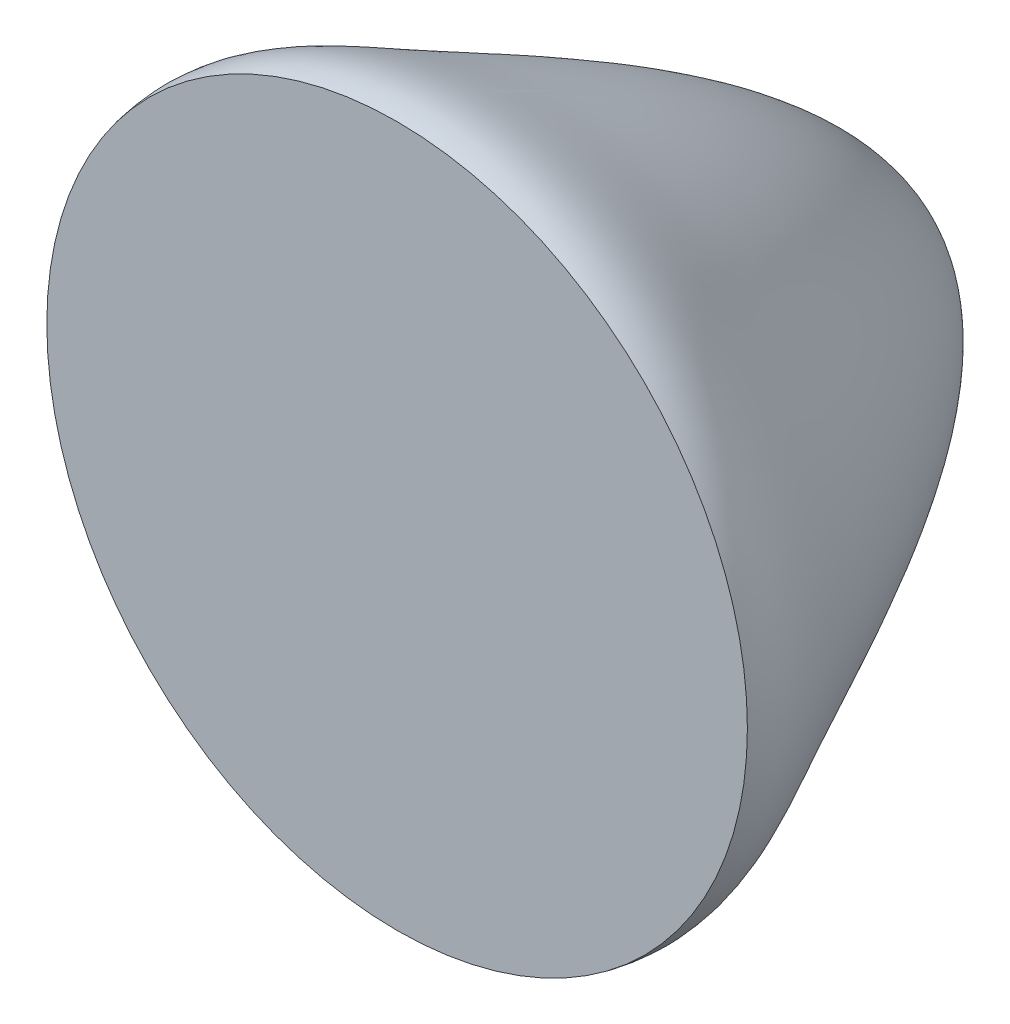
from build123d import *


with BuildPart() as part:
    # Sketch2 → Revolve1 (revolve)
    with BuildSketch(Plane(origin=(0, 0, 0), x_dir=(0, 0, -1), z_dir=(1, 0, 0))):
        with BuildLine():
            Line((0, 0.8), (0, 0))
            Line((0, 0), (1.15, 0))
            add(Edge.make_bspline(
                [(0, 0.8), (0.098891587, 0.821380604), (0.321650497, 0.679588811), (1.15, 0.319733684), (1.15, 0)],
                knots=[0, 0, 0, 0, 0.365919055, 1, 1, 1, 1], degree=3))
        make_face()
    revolve(axis=Axis((0, 0, -1.15), (0, 0, 1)))


solid = part.part
